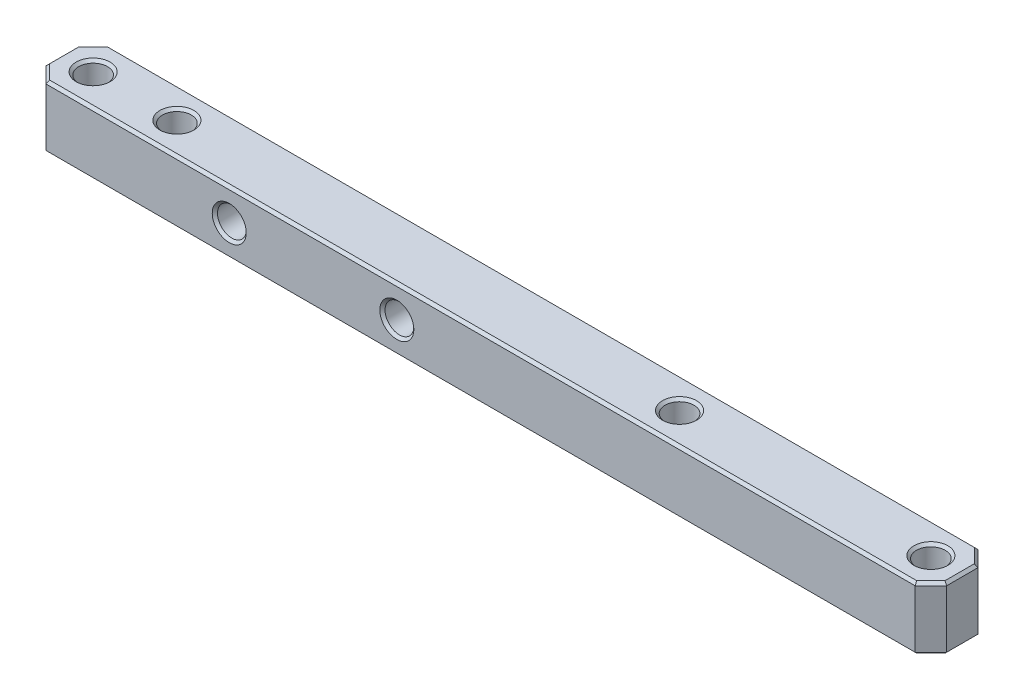
from build123d import *

# Parameters (mm, degrees)
SKETCH1_W               = 136.525
SKETCH1_H               = 9.525
SKETCH1_R               = 2.1828125
BOSS_EXTRUDE1_DEPTH     = 9.525
SKETCH2_R               = 2.1828125
CUT_EXTRUDE1_DEPTH      = 1
CUT_EXTRUDE1_DEPTH_BACK = 10.525
CHAMFER1_SIZE           = 2.38125
CHAMFER2_SIZE           = 0.396875


with BuildPart() as part:
    # Sketch1 → Boss-Extrude1 (new body)
    with BuildSketch(Plane(origin=(0, 0, 0), x_dir=(1, 0, 0), z_dir=(0, 1, 0))):
        with Locations((63.5, 0)):
            Rectangle(SKETCH1_W, SKETCH1_H)
        Circle(SKETCH1_R, mode=Mode.SUBTRACT)
        with Locations((12.7, 0)):
            Circle(SKETCH1_R, mode=Mode.SUBTRACT)
        with Locations((127, 0)):
            Circle(SKETCH1_R, mode=Mode.SUBTRACT)
        with Locations((88.9, 0)):
            Circle(SKETCH1_R, mode=Mode.SUBTRACT)
    extrude(amount=BOSS_EXTRUDE1_DEPTH)

    # Sketch2 → Cut-Extrude1 (cut, two sides)
    with BuildSketch(Plane.XY.offset(4.7625)) as cut_extrude1_sk:
        with Locations((25.4, 4.7625)):
            Circle(SKETCH2_R)
        with Locations((50.8, 4.7625)):
            Circle(SKETCH2_R)
    extrude(amount=CUT_EXTRUDE1_DEPTH, mode=Mode.SUBTRACT)
    extrude(cut_extrude1_sk.sketch, amount=-CUT_EXTRUDE1_DEPTH_BACK, mode=Mode.SUBTRACT)

    # Chamfer1
    chamfer1_edges = [part.edges().sort_by_distance(p)[0] for p in [
        (-4.7625, 4.7625, -4.7625),
        (131.7625, 4.7625, -4.7625),
        (131.7625, 4.7625, 4.7625),
        (-4.7625, 4.7625, 4.7625),
    ]]
    chamfer(chamfer1_edges, length=CHAMFER1_SIZE)

    # Chamfer2
    chamfer2_edges = [part.edges().sort_by_distance(p)[0] for p in [
        (-2.1828125, 0, 0),
        (-2.1828125, 9.525, 0),
        (10.5171875, 0, 0),
        (10.5171875, 9.525, 0),
        (124.8171875, 0, 0),
        (124.8171875, 9.525, 0),
        (86.7171875, 0, 0),
        (86.7171875, 9.525, 0),
        (23.2171875, 4.7625, -4.7625),
        (23.2171875, 4.7625, 4.7625),
        (48.6171875, 4.7625, -4.7625),
        (48.6171875, 4.7625, 4.7625),
        (63.5, 0, -4.7625),
        (63.5, 9.525, -4.7625),
        (-4.7625, 0, 0),
        (131.7625, 0, 0),
        (63.5, 0, 4.7625),
        (-3.571875, 0, 3.571875),
        (-3.571875, 0, -3.571875),
        (130.571875, 0, 3.571875),
        (130.571875, 0, -3.571875),
        (131.7625, 9.525, 0),
        (-4.7625, 9.525, 0),
        (63.5, 9.525, 4.7625),
        (-3.571875, 9.525, 3.571875),
        (-3.571875, 9.525, -3.571875),
        (130.571875, 9.525, 3.571875),
        (130.571875, 9.525, -3.571875),
    ]]
    chamfer(chamfer2_edges, length=CHAMFER2_SIZE)


solid = part.part
